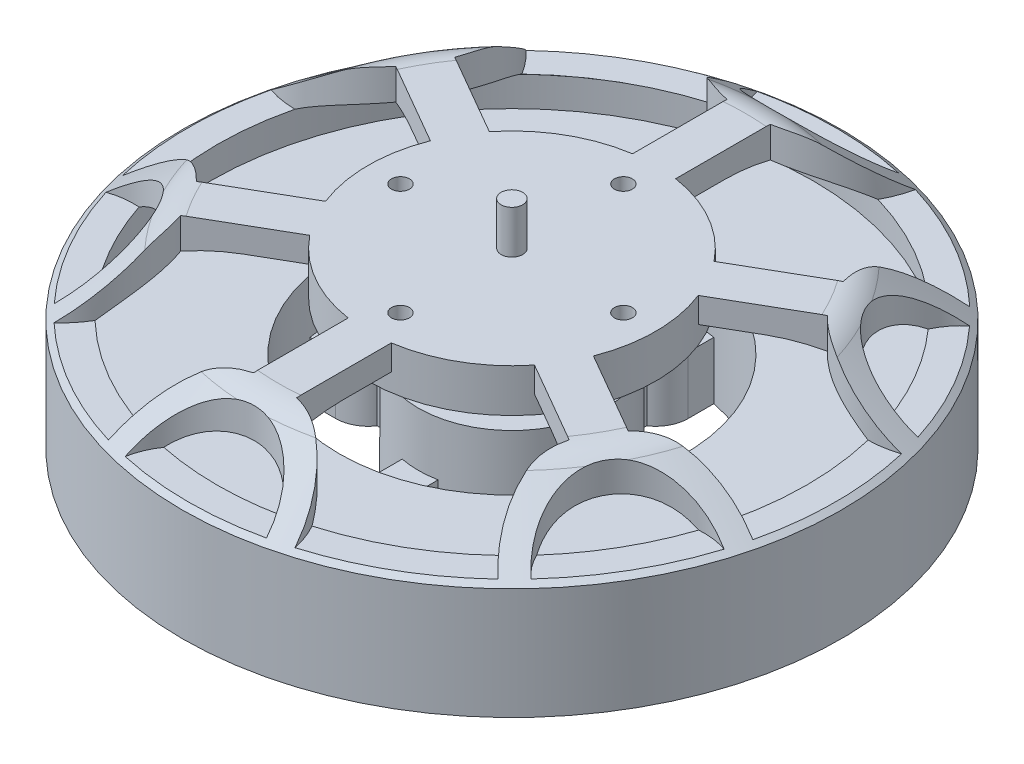
from build123d import *

# Parameters (mm, degrees)
M4X0_7_TAPPED_HOLE1_D     = 3.3
M4X0_7_TAPPED_HOLE1_DEPTH = 8.000009
M4X0_7_TAPPED_HOLE1_TIP   = 0.99142
CUT_EXTRUDE1_DEPTH        = 8
CUT_EXTRUDE3_START        = 32.18
SKETCH6_OUTSIDE_W         = 120.686
SKETCH6_OUTSIDE_H         = 120.686
CUT_EXTRUDE3_DEPTH        = 8
M3X0_5_TAPPED_HOLE1_D     = 2.5
M3X0_5_TAPPED_HOLE1_DEPTH = 6
BOSS_EXTRUDE1_START       = 12.7
BOSS_EXTRUDE1_DEPTH       = 19.05


with BuildPart() as part:
    # Sketch1 → Revolve1 (revolve)
    with BuildSketch(Plane.XY):
        with BuildLine():
            Line((0, 0), (9.65, 0))
            Line((9.65, 0), (9.65, 3.93))
            Line((9.65, 3.93), (27.5, 3.93))
            Line((27.5, 3.93), (45.83, 8.08))
            Line((45.83, 8.08), (45.83, 23.58))
            Line((45.83, 23.58), (36.13217, 30.955703))
            ThreePointArc((36.13217, 30.955703), (34.416479, 31.865693), (32.5, 32.18))
            Line((32.5, 32.18), (1.5, 32.18))
            Line((1.5, 32.18), (1.5, 38.18))
            Line((1.5, 38.18), (0, 38.18))
            Line((0, 38.18), (0, 0))
        make_face()
    revolve(axis=Axis((0, 38.18, 0), (0, -1, 0)))

    # M4x0.7 Tapped Hole1
    with Locations(Plane(origin=(-20, 3.93, 0), x_dir=(0, 0, -1), z_dir=(0, -1, 0))):
        with Locations((0, 0), (-20, 20), (0, 40), (20, 20)):
            Hole(M4X0_7_TAPPED_HOLE1_D / 2, depth=M4X0_7_TAPPED_HOLE1_DEPTH)
            with Locations((0, 0, -(M4X0_7_TAPPED_HOLE1_DEPTH + M4X0_7_TAPPED_HOLE1_TIP / 2))):  # 118° drill point
                Cone(0, M4X0_7_TAPPED_HOLE1_D / 2, M4X0_7_TAPPED_HOLE1_TIP, mode=Mode.SUBTRACT)

    # Sketch2 → Cut-Extrude1 (cut)
    with BuildSketch(Plane.XZ.offset(-3.93)):
        with BuildLine():
            Line((2.5, 12.757351), (2.5, 16.258343))
            ThreePointArc((2.5, 16.258343), (3.968627, 17.87868), (4.5, 20))
            Line((4.5, 20), (4.5, 23.57435))
            ThreePointArc((4.5, 23.57435), (16.970563, 16.970563), (23.57435, 4.5))
            Line((23.57435, 4.5), (20, 4.5))
            ThreePointArc((20, 4.5), (17.87868, 3.968627), (16.258343, 2.5))
            Line((16.258343, 2.5), (12.757351, 2.5))
            ThreePointArc((12.757351, 2.5), (9.192388, 9.192388), (2.5, 12.757351))
        make_face()
        with BuildLine():
            Line((20, -4.5), (23.57435, -4.5))
            ThreePointArc((23.57435, -4.5), (16.970563, -16.970563), (4.5, -23.57435))
            Line((4.5, -23.57435), (4.5, -20))
            ThreePointArc((4.5, -20), (3.968627, -17.87868), (2.5, -16.258343))
            Line((2.5, -16.258343), (2.5, -12.757351))
            ThreePointArc((2.5, -12.757351), (9.192388, -9.192388), (12.757351, -2.5))
            Line((12.757351, -2.5), (16.258343, -2.5))
            ThreePointArc((16.258343, -2.5), (17.87868, -3.968627), (20, -4.5))
        make_face()
        with BuildLine():
            Line((-4.5, -20), (-4.5, -23.57435))
            ThreePointArc((-4.5, -23.57435), (-16.970563, -16.970563), (-23.57435, -4.5))
            Line((-23.57435, -4.5), (-20, -4.5))
            ThreePointArc((-20, -4.5), (-17.87868, -3.968627), (-16.258343, -2.5))
            Line((-16.258343, -2.5), (-12.757351, -2.5))
            ThreePointArc((-12.757351, -2.5), (-9.192388, -9.192388), (-2.5, -12.757351))
            Line((-2.5, -12.757351), (-2.5, -16.258343))
            ThreePointArc((-2.5, -16.258343), (-3.968627, -17.87868), (-4.5, -20))
        make_face()
        with BuildLine():
            Line((-20, 4.5), (-23.57435, 4.5))
            ThreePointArc((-23.57435, 4.5), (-16.970563, 16.970563), (-4.5, 23.57435))
            Line((-4.5, 23.57435), (-4.5, 20))
            ThreePointArc((-4.5, 20), (-3.968627, 17.87868), (-2.5, 16.258343))
            Line((-2.5, 16.258343), (-2.5, 12.757351))
            ThreePointArc((-2.5, 12.757351), (-9.192388, 9.192388), (-12.757351, 2.5))
            Line((-12.757351, 2.5), (-16.258343, 2.5))
            ThreePointArc((-16.258343, 2.5), (-17.87868, 3.968627), (-20, 4.5))
        make_face()
    extrude(amount=-CUT_EXTRUDE1_DEPTH, mode=Mode.SUBTRACT)

    # Sketch5 → Cut-Revolve3 (revolve, cut)
    with BuildSketch(Plane.XY):
        with BuildLine():
            Line((24, 19.43), (41.83, 19.43))
            Line((41.83, 19.43), (41.83, 23.58))
            ThreePointArc((41.83, 23.58), (34.683019, 27.370707), (26.699628, 28.68))
            Line((26.699628, 28.68), (20, 28.68))
            Line((20, 28.68), (20, 26.18))
            Line((20, 26.18), (10, 26.18))
            Line((10, 26.18), (10, 19.43))
            Line((10, 19.43), (13, 19.43))
            Line((13, 19.43), (13, 11.93))
            Line((13, 11.93), (24, 11.93))
            Line((24, 11.93), (24, 19.43))
        make_face()
    revolve(axis=Axis((0, 40.089, 0), (0, -1, 0)), mode=Mode.SUBTRACT)

    # Sketch6 outside → Cut-Extrude3 (cut)
    with BuildSketch(Plane(origin=(0, 0, 0), x_dir=(1, 0, 0), z_dir=(0, 1, 0)).offset(CUT_EXTRUDE3_START)):
        Rectangle(SKETCH6_OUTSIDE_W, SKETCH6_OUTSIDE_H)
        with BuildLine():
            Line((-3, 19.77372), (-3, 32.924091))
            ThreePointArc((-3, 32.924091), (-9.751293, 36.859226), (-13.11083, 43.914633))
            ThreePointArc((-13.11083, 43.914633), (-11.532938, 44.35516), (-9.940309, 44.739012))
            ThreePointArc((-9.940309, 44.739012), (0, 35.83), (9.940309, 44.739012))
            ThreePointArc((9.940309, 44.739012), (11.532938, 44.35516), (13.11083, 43.914633))
            ThreePointArc((13.11083, 43.914633), (9.751293, 36.859226), (3, 32.924091))
            Line((3, 32.924091), (3, 19.77372))
            ThreePointArc((3, 19.77372), (10, 17.320508), (15.624544, 12.484936))
            Line((15.624544, 12.484936), (27.013099, 19.060121))
            ThreePointArc((27.013099, 19.060121), (27.04538, 26.874481), (31.475773, 33.311629))
            ThreePointArc((31.475773, 33.311629), (32.646227, 32.165397), (33.774966, 30.978066))
            ThreePointArc((33.774966, 30.978066), (31.02969, 17.915), (43.715275, 13.760946))
            ThreePointArc((43.715275, 13.760946), (44.179165, 12.189763), (44.586603, 10.603005))
            ThreePointArc((44.586603, 10.603005), (36.796673, 9.984745), (30.013099, 13.863969))
            Line((30.013099, 13.863969), (18.624544, 7.288784))
            ThreePointArc((18.624544, 7.288784), (20, 0), (18.624544, -7.288784))
            Line((18.624544, -7.288784), (30.013099, -13.863969))
            ThreePointArc((30.013099, -13.863969), (36.796673, -9.984745), (44.586603, -10.603005))
            ThreePointArc((44.586603, -10.603005), (44.179165, -12.189763), (43.715275, -13.760946))
            ThreePointArc((43.715275, -13.760946), (31.02969, -17.915), (33.774966, -30.978066))
            ThreePointArc((33.774966, -30.978066), (32.646227, -32.165397), (31.475773, -33.311629))
            ThreePointArc((31.475773, -33.311629), (27.04538, -26.874481), (27.013099, -19.060121))
            Line((27.013099, -19.060121), (15.624544, -12.484936))
            ThreePointArc((15.624544, -12.484936), (10, -17.320508), (3, -19.77372))
            Line((3, -19.77372), (3, -32.924091))
            ThreePointArc((3, -32.924091), (9.751293, -36.859226), (13.11083, -43.914633))
            ThreePointArc((13.11083, -43.914633), (11.532938, -44.35516), (9.940309, -44.739012))
            ThreePointArc((9.940309, -44.739012), (0, -35.83), (-9.940309, -44.739012))
            ThreePointArc((-9.940309, -44.739012), (-11.532938, -44.35516), (-13.11083, -43.914633))
            ThreePointArc((-13.11083, -43.914633), (-9.751293, -36.859226), (-3, -32.924091))
            Line((-3, -32.924091), (-3, -19.77372))
            ThreePointArc((-3, -19.77372), (-10, -17.320508), (-15.624544, -12.484936))
            Line((-15.624544, -12.484936), (-27.013099, -19.060121))
            ThreePointArc((-27.013099, -19.060121), (-27.04538, -26.874481), (-31.475773, -33.311629))
            ThreePointArc((-31.475773, -33.311629), (-32.646227, -32.165397), (-33.774966, -30.978066))
            ThreePointArc((-33.774966, -30.978066), (-31.02969, -17.915), (-43.715275, -13.760946))
            ThreePointArc((-43.715275, -13.760946), (-44.179165, -12.189763), (-44.586603, -10.603005))
            ThreePointArc((-44.586603, -10.603005), (-36.796673, -9.984745), (-30.013099, -13.863969))
            Line((-30.013099, -13.863969), (-18.624544, -7.288784))
            ThreePointArc((-18.624544, -7.288784), (-20, 0), (-18.624544, 7.288784))
            Line((-18.624544, 7.288784), (-30.013099, 13.863969))
            ThreePointArc((-30.013099, 13.863969), (-36.796673, 9.984745), (-44.586603, 10.603005))
            ThreePointArc((-44.586603, 10.603005), (-44.179165, 12.189763), (-43.715275, 13.760946))
            ThreePointArc((-43.715275, 13.760946), (-31.02969, 17.915), (-33.774966, 30.978066))
            ThreePointArc((-33.774966, 30.978066), (-32.646227, 32.165397), (-31.475773, 33.311629))
            ThreePointArc((-31.475773, 33.311629), (-27.04538, 26.874481), (-27.013099, 19.060121))
            Line((-27.013099, 19.060121), (-15.624544, 12.484936))
            ThreePointArc((-15.624544, 12.484936), (-10, 17.320508), (-3, 19.77372))
        make_face(mode=Mode.SUBTRACT)
    extrude(amount=-CUT_EXTRUDE3_DEPTH, mode=Mode.SUBTRACT)

    # M3x0.5 Tapped Hole1
    with Locations(Plane(origin=(0, 32.18, 0), x_dir=(1, 0, 0), z_dir=(0, 1, 0))):
        with Locations((0, 15.5), (15.5, 0), (0, -15.5), (-15.5, 0)):
            Hole(M3X0_5_TAPPED_HOLE1_D / 2, depth=M3X0_5_TAPPED_HOLE1_DEPTH)

    # Sketch11 → Boss-Extrude1 (add)
    with BuildSketch(Plane(origin=(0, 0, 0), x_dir=(1, 0, 0), z_dir=(0, 1, 0)).offset(BOSS_EXTRUDE1_START)):
        with BuildLine():
            Line((-27.987286, 23.391092), (-23.391092, 27.987286))
            ThreePointArc((-23.391092, 27.987286), (-19.502005, 27.987286), (-19.502005, 24.098199))
            Line((-19.502005, 24.098199), (-24.098199, 19.502005))
            ThreePointArc((-24.098199, 19.502005), (-27.987286, 19.502005), (-27.987286, 23.391092))
        make_face()
    extrude(amount=-BOSS_EXTRUDE1_DEPTH)


solid = part.part
